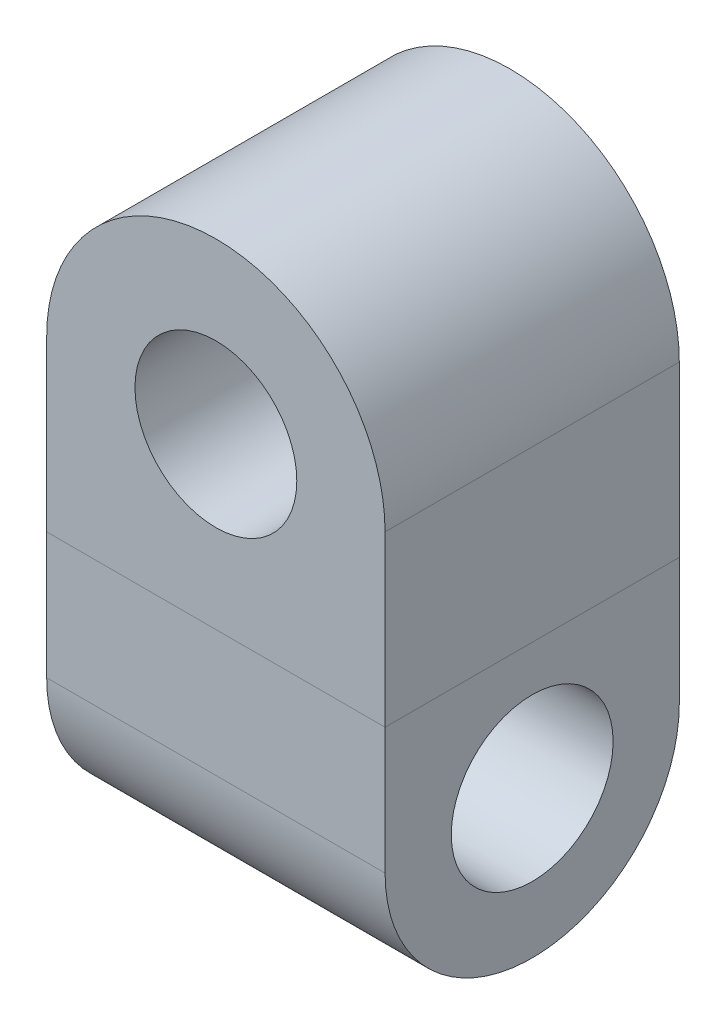
from build123d import *

# Parameters (mm, degrees)
SKETCH1_R           = 1.397
BOSS_EXTRUDE1_DEPTH = 5.08
SKETCH2_R           = 1.397
BOSS_EXTRUDE2_DEPTH = 2.921


with BuildPart() as part:
    # Sketch1 → Boss-Extrude1 (new body)
    with BuildSketch(Plane.XY):
        with BuildLine():
            Line((-2.921, 0), (-2.921, -2.921))
            Line((-2.921, -2.921), (2.921, -2.921))
            Line((2.921, -2.921), (2.921, 0))
            ThreePointArc((2.921, 0), (0, 2.921), (-2.921, 0))
        make_face()
        Circle(SKETCH1_R, mode=Mode.SUBTRACT)
    extrude(amount=BOSS_EXTRUDE1_DEPTH)


with BuildPart() as body_2:
    # Sketch2 → Boss-Extrude2 (new body, symmetric)
    with BuildSketch(Plane(origin=(0, 0, 0), x_dir=(0, 0, -1), z_dir=(1, 0, 0))):
        with BuildLine():
            Line((-5.08, -2.921), (0, -2.921))
            Line((0, -2.921), (0, -5.101837624))
            ThreePointArc((0, -5.101837624), (-2.54, -7.641837624), (-5.08, -5.101837624))
            Line((-5.08, -5.101837624), (-5.08, -2.921))
        make_face()
        with Locations((-2.54, -5.101837624)):
            Circle(SKETCH2_R, mode=Mode.SUBTRACT)
    extrude(amount=BOSS_EXTRUDE2_DEPTH, both=True)


solid = Compound([part.part, body_2.part])
